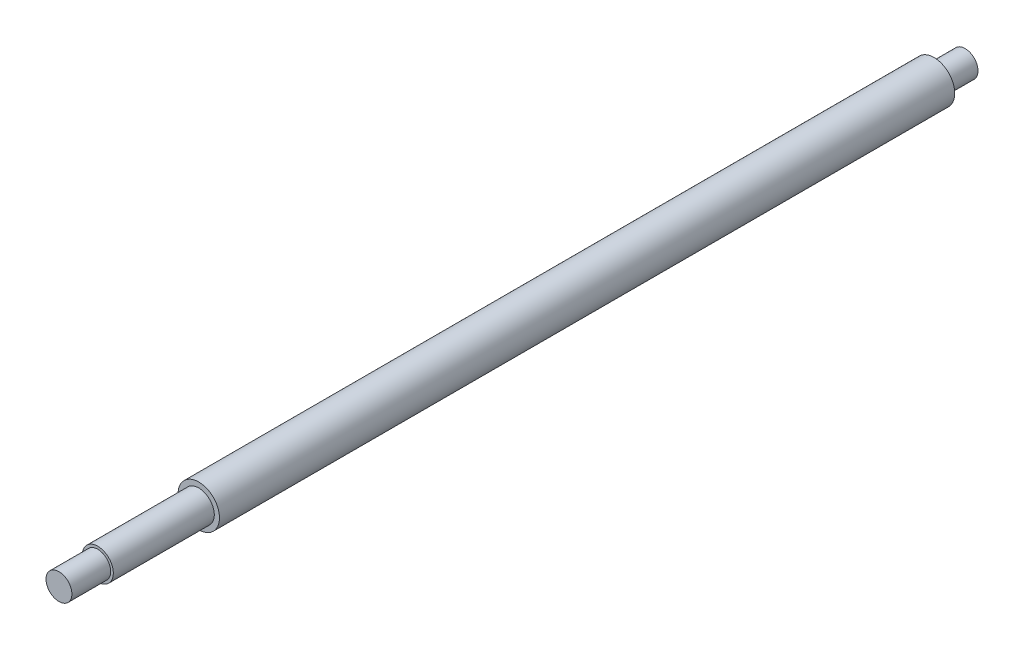
from build123d import *


with BuildPart() as part:
    # Sketch1 → Revolve1 (revolve)
    with BuildSketch(Plane(origin=(0, 0, 0), x_dir=(0, 0, -1), z_dir=(1, 0, 0))):
        Polygon((-338.68, 0), (-338.68, 5), (-323.68, 5), (-323.68, 6), (-284.68, 6), (-284.68, 8), (-0.68, 8), (-0.68, 5), (11.32, 5), (11.32, 0), align=None)
    revolve(axis=Axis((0, 0, 0), (0, 0, 1)))


solid = part.part
